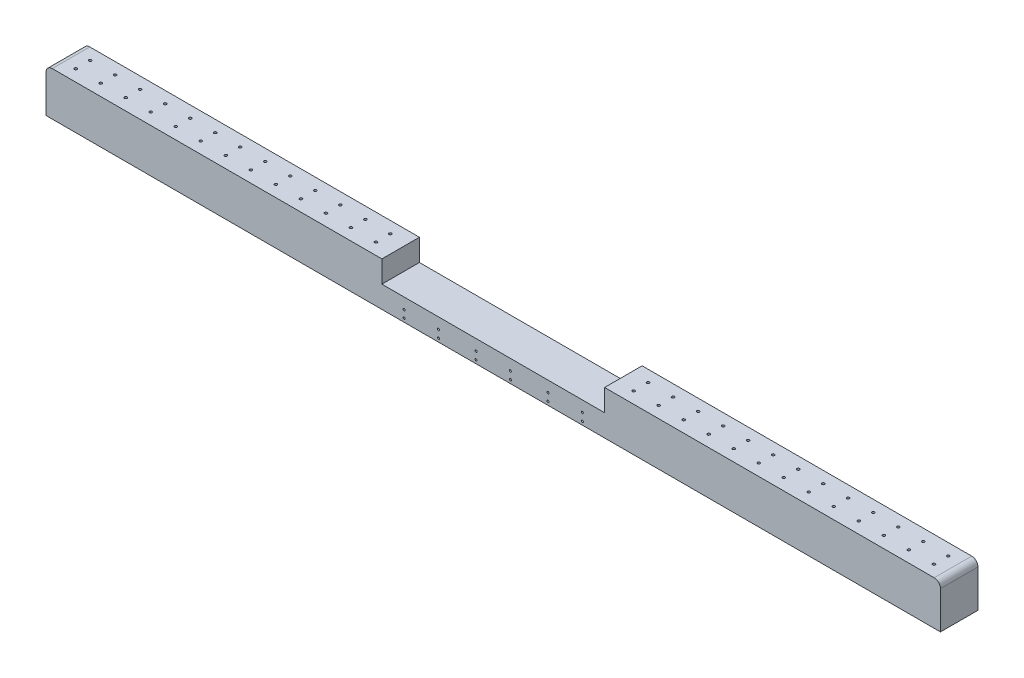
from build123d import *

# Parameters (mm, degrees)
SKETCH1_W                      = 1430
SKETCH1_H                      = 60
BOSS_EXTRUDE1_DEPTH            = 35
SKETCH2_W                      = 356
SKETCH2_H                      = 60
CUT_EXTRUDE1_DEPTH             = 35
M5X0_8_TAPPED_HOLE2_D          = 4.2
LPATTERN1_COUNT                = 13
LPATTERN1_PITCH                = 40
MIRROR1_COPY_1_D               = 4.2
MIRROR1_COPY_2_D               = 4.2
MIRROR1_COPY_3_D               = 4.2
MIRROR1_COPY_4_D               = 4.2
MIRROR1_COPY_5_D               = 4.2
MIRROR1_COPY_6_D               = 4.2
MIRROR1_COPY_7_D               = 4.2
MIRROR1_COPY_8_D               = 4.2
MIRROR1_COPY_9_D               = 4.2
MIRROR1_COPY_10_D              = 4.2
MIRROR1_COPY_11_D              = 4.2
MIRROR1_COPY_12_D              = 4.2
M4X0_7_TAPPED_HOLE1_AT_2_COUNT = 2
M4X0_7_TAPPED_HOLE1_AT_2_PITCH = 12
M4X0_7_TAPPED_HOLE1_AT_3_COUNT = 2
M4X0_7_TAPPED_HOLE1_AT_3_PITCH = 55
M4X0_7_TAPPED_HOLE1_AT_4_COUNT = 2
M4X0_7_TAPPED_HOLE1_AT_4_PITCH = 56.29387178
M4X0_7_TAPPED_HOLE1_AT_5_COUNT = 2
M4X0_7_TAPPED_HOLE1_AT_5_PITCH = 115
M4X0_7_TAPPED_HOLE1_AT_6_COUNT = 2
M4X0_7_TAPPED_HOLE1_AT_6_PITCH = 115.62439189
FILLET1_R                      = 10


with BuildPart() as part:
    # Sketch1 → Boss-Extrude1 (new body, symmetric)
    with BuildSketch(Plane(origin=(0, 0, 0), x_dir=(1, 0, 0), z_dir=(0, 1, 0))):
        Rectangle(SKETCH1_W, SKETCH1_H)
    extrude(amount=BOSS_EXTRUDE1_DEPTH, both=True)

    # Sketch2 → Cut-Extrude1 (cut)
    with BuildSketch(Plane(origin=(0, 35, 0), x_dir=(1, 0, 0), z_dir=(0, 1, 0))):
        Rectangle(SKETCH2_W, SKETCH2_H)
    extrude(amount=-CUT_EXTRUDE1_DEPTH, mode=Mode.SUBTRACT)

    # M5x0.8 Tapped Hole2 (through all)
    with Locations(Plane(origin=(0, 35, 0), x_dir=(1, 0, 0), z_dir=(0, 1, 0))):
        with Locations((205.9918251, 11.5), (205.9918251, -11.5)):
            m5x0_8_tapped_hole2 = Hole(M5X0_8_TAPPED_HOLE2_D / 2)

    # LPattern1: M5x0.8 Tapped Hole2 ×13
    with Locations(*[(i * LPATTERN1_PITCH, 0, 0) for i in range(1, LPATTERN1_COUNT)]):
        add(m5x0_8_tapped_hole2, mode=Mode.SUBTRACT)

    # Mirror1: M5x0.8 Tapped Hole2 across plane
    add(m5x0_8_tapped_hole2.mirror(Plane(origin=(0, 0, 0), x_dir=(0, 0, 1), z_dir=(1, 0, 0))), mode=Mode.SUBTRACT)

    # Mirror1 copy 1 (through all)
    with Locations(Plane(origin=(-40, 35, 0), x_dir=(-1, 0, 0), z_dir=(0, 1, 0))):
        with Locations((205.9918251, -11.5), (205.9918251, 11.5)):
            Hole(MIRROR1_COPY_1_D / 2)

    # Mirror1 copy 2 (through all)
    with Locations(Plane(origin=(-80, 35, 0), x_dir=(-1, 0, 0), z_dir=(0, 1, 0))):
        with Locations((205.9918251, -11.5), (205.9918251, 11.5)):
            Hole(MIRROR1_COPY_2_D / 2)

    # Mirror1 copy 3 (through all)
    with Locations(Plane(origin=(-120, 35, 0), x_dir=(-1, 0, 0), z_dir=(0, 1, 0))):
        with Locations((205.9918251, -11.5), (205.9918251, 11.5)):
            Hole(MIRROR1_COPY_3_D / 2)

    # Mirror1 copy 4 (through all)
    with Locations(Plane(origin=(-160, 35, 0), x_dir=(-1, 0, 0), z_dir=(0, 1, 0))):
        with Locations((205.9918251, -11.5), (205.9918251, 11.5)):
            Hole(MIRROR1_COPY_4_D / 2)

    # Mirror1 copy 5 (through all)
    with Locations(Plane(origin=(-200, 35, 0), x_dir=(-1, 0, 0), z_dir=(0, 1, 0))):
        with Locations((205.9918251, -11.5), (205.9918251, 11.5)):
            Hole(MIRROR1_COPY_5_D / 2)

    # Mirror1 copy 6 (through all)
    with Locations(Plane(origin=(-240, 35, 0), x_dir=(-1, 0, 0), z_dir=(0, 1, 0))):
        with Locations((205.9918251, -11.5), (205.9918251, 11.5)):
            Hole(MIRROR1_COPY_6_D / 2)

    # Mirror1 copy 7 (through all)
    with Locations(Plane(origin=(-280, 35, 0), x_dir=(-1, 0, 0), z_dir=(0, 1, 0))):
        with Locations((205.9918251, -11.5), (205.9918251, 11.5)):
            Hole(MIRROR1_COPY_7_D / 2)

    # Mirror1 copy 8 (through all)
    with Locations(Plane(origin=(-320, 35, 0), x_dir=(-1, 0, 0), z_dir=(0, 1, 0))):
        with Locations((205.9918251, -11.5), (205.9918251, 11.5)):
            Hole(MIRROR1_COPY_8_D / 2)

    # Mirror1 copy 9 (through all)
    with Locations(Plane(origin=(-360, 35, 0), x_dir=(-1, 0, 0), z_dir=(0, 1, 0))):
        with Locations((205.9918251, -11.5), (205.9918251, 11.5)):
            Hole(MIRROR1_COPY_9_D / 2)

    # Mirror1 copy 10 (through all)
    with Locations(Plane(origin=(-400, 35, 0), x_dir=(-1, 0, 0), z_dir=(0, 1, 0))):
        with Locations((205.9918251, -11.5), (205.9918251, 11.5)):
            Hole(MIRROR1_COPY_10_D / 2)

    # Mirror1 copy 11 (through all)
    with Locations(Plane(origin=(-440, 35, 0), x_dir=(-1, 0, 0), z_dir=(0, 1, 0))):
        with Locations((205.9918251, -11.5), (205.9918251, 11.5)):
            Hole(MIRROR1_COPY_11_D / 2)

    # Mirror1 copy 12 (through all)
    with Locations(Plane(origin=(-480, 35, 0), x_dir=(-1, 0, 0), z_dir=(0, 1, 0))):
        with Locations((205.9918251, -11.5), (205.9918251, 11.5)):
            Hole(MIRROR1_COPY_12_D / 2)

    # Sketch10 → M4x0.7 Tapped Hole1 (revolve, cut)
    with BuildSketch(Plane(origin=(142.5, -17.5, 30), x_dir=(0, -1, 0), z_dir=(1, 0, 0))):
        Polygon((0, 0), (0, 15.991420021), (1.65, 15), (1.65, 0), align=None)
    m4x0_7_tapped_hole1 = revolve(axis=Axis((142.5, -17.5, 36.35), (0, 0, -1)), mode=Mode.SUBTRACT)

    # M4x0.7 Tapped Hole1 at 2: M4x0.7 Tapped Hole1 ×2
    with Locations(*[(0, -i * M4X0_7_TAPPED_HOLE1_AT_2_PITCH, 0) for i in range(1, M4X0_7_TAPPED_HOLE1_AT_2_COUNT)]):
        add(m4x0_7_tapped_hole1, mode=Mode.SUBTRACT)

    # M4x0.7 Tapped Hole1 at 3: M4x0.7 Tapped Hole1 ×2
    with Locations(*[(-i * M4X0_7_TAPPED_HOLE1_AT_3_PITCH, 0, 0) for i in range(1, M4X0_7_TAPPED_HOLE1_AT_3_COUNT)]):
        add(m4x0_7_tapped_hole1, mode=Mode.SUBTRACT)

    # M4x0.7 Tapped Hole1 at 4: M4x0.7 Tapped Hole1 ×2
    with Locations(*[Vector(-0.977015761, -0.213167075, 0) * (i * M4X0_7_TAPPED_HOLE1_AT_4_PITCH) for i in range(1, M4X0_7_TAPPED_HOLE1_AT_4_COUNT)]):
        add(m4x0_7_tapped_hole1, mode=Mode.SUBTRACT)

    # M4x0.7 Tapped Hole1 at 5: M4x0.7 Tapped Hole1 ×2
    with Locations(*[(-i * M4X0_7_TAPPED_HOLE1_AT_5_PITCH, 0, 0) for i in range(1, M4X0_7_TAPPED_HOLE1_AT_5_COUNT)]):
        add(m4x0_7_tapped_hole1, mode=Mode.SUBTRACT)

    # M4x0.7 Tapped Hole1 at 6: M4x0.7 Tapped Hole1 ×2
    with Locations(*[Vector(-0.994599826, -0.10378433, 0) * (i * M4X0_7_TAPPED_HOLE1_AT_6_PITCH) for i in range(1, M4X0_7_TAPPED_HOLE1_AT_6_COUNT)]):
        add(m4x0_7_tapped_hole1, mode=Mode.SUBTRACT)

    # Mirror2: M4x0.7 Tapped Hole1 across plane
    add(m4x0_7_tapped_hole1.mirror(Plane(origin=(0, 0, 0), x_dir=(0, 0, 1), z_dir=(1, 0, 0))), mode=Mode.SUBTRACT)

    # Mirror2 copy 1 sketch → Mirror2 copy 1 (revolve, cut)
    with BuildSketch(Plane(origin=(-142.5, -29.5, 30), x_dir=(0, -1, 0), z_dir=(-1, 0, 0))):
        Polygon((0, 0), (0, -15.991420021), (1.65, -15), (1.65, 0), align=None)
    revolve(axis=Axis((-142.5, -29.5, 36.35), (0, 0, 1)), mode=Mode.SUBTRACT)

    # Mirror2 copy 2 sketch → Mirror2 copy 2 (revolve, cut)
    with BuildSketch(Plane(origin=(-87.5, -17.5, 30), x_dir=(0, -1, 0), z_dir=(-1, 0, 0))):
        Polygon((0, 0), (0, -15.991420021), (1.65, -15), (1.65, 0), align=None)
    revolve(axis=Axis((-87.5, -17.5, 36.35), (0, 0, 1)), mode=Mode.SUBTRACT)

    # Mirror2 copy 3 sketch → Mirror2 copy 3 (revolve, cut)
    with BuildSketch(Plane(origin=(-87.5, -29.5, 30), x_dir=(0, -1, 0), z_dir=(-1, 0, 0))):
        Polygon((0, 0), (0, -15.991420021), (1.65, -15), (1.65, 0), align=None)
    revolve(axis=Axis((-87.5, -29.5, 36.35), (0, 0, 1)), mode=Mode.SUBTRACT)

    # Mirror2 copy 4 sketch → Mirror2 copy 4 (revolve, cut)
    with BuildSketch(Plane(origin=(-27.5, -17.5, 30), x_dir=(0, -1, 0), z_dir=(-1, 0, 0))):
        Polygon((0, 0), (0, -15.991420021), (1.65, -15), (1.65, 0), align=None)
    revolve(axis=Axis((-27.5, -17.5, 36.35), (0, 0, 1)), mode=Mode.SUBTRACT)

    # Mirror2 copy 5 sketch → Mirror2 copy 5 (revolve, cut)
    with BuildSketch(Plane(origin=(-27.5, -29.5, 30), x_dir=(0, -1, 0), z_dir=(-1, 0, 0))):
        Polygon((0, 0), (0, -15.991420021), (1.65, -15), (1.65, 0), align=None)
    revolve(axis=Axis((-27.5, -29.5, 36.35), (0, 0, 1)), mode=Mode.SUBTRACT)

    # Mirror3: M4x0.7 Tapped Hole1 across plane
    add(m4x0_7_tapped_hole1.mirror(Plane.XY), mode=Mode.SUBTRACT)

    # Mirror3 copy 1 sketch → Mirror3 copy 1 (revolve, cut)
    with BuildSketch(Plane(origin=(-142.5, -17.5, -30), x_dir=(0, -1, 0), z_dir=(-1, 0, 0))):
        Polygon((0, 0), (0, 15.991420021), (1.65, 15), (1.65, 0), align=None)
    revolve(axis=Axis((-142.5, -17.5, -36.35), (0, 0, 1)), mode=Mode.SUBTRACT)

    # Mirror3 copy 2 sketch → Mirror3 copy 2 (revolve, cut)
    with BuildSketch(Plane(origin=(-142.5, -29.5, -30), x_dir=(0, -1, 0), z_dir=(-1, 0, 0))):
        Polygon((0, 0), (0, 15.991420021), (1.65, 15), (1.65, 0), align=None)
    revolve(axis=Axis((-142.5, -29.5, -36.35), (0, 0, 1)), mode=Mode.SUBTRACT)

    # Mirror3 copy 3 sketch → Mirror3 copy 3 (revolve, cut)
    with BuildSketch(Plane(origin=(-87.5, -17.5, -30), x_dir=(0, -1, 0), z_dir=(-1, 0, 0))):
        Polygon((0, 0), (0, 15.991420021), (1.65, 15), (1.65, 0), align=None)
    revolve(axis=Axis((-87.5, -17.5, -36.35), (0, 0, 1)), mode=Mode.SUBTRACT)

    # Mirror3 copy 4 sketch → Mirror3 copy 4 (revolve, cut)
    with BuildSketch(Plane(origin=(-87.5, -29.5, -30), x_dir=(0, -1, 0), z_dir=(-1, 0, 0))):
        Polygon((0, 0), (0, 15.991420021), (1.65, 15), (1.65, 0), align=None)
    revolve(axis=Axis((-87.5, -29.5, -36.35), (0, 0, 1)), mode=Mode.SUBTRACT)

    # Mirror3 copy 5 sketch → Mirror3 copy 5 (revolve, cut)
    with BuildSketch(Plane(origin=(-27.5, -17.5, -30), x_dir=(0, -1, 0), z_dir=(-1, 0, 0))):
        Polygon((0, 0), (0, 15.991420021), (1.65, 15), (1.65, 0), align=None)
    revolve(axis=Axis((-27.5, -17.5, -36.35), (0, 0, 1)), mode=Mode.SUBTRACT)

    # Mirror3 copy 6 sketch → Mirror3 copy 6 (revolve, cut)
    with BuildSketch(Plane(origin=(-27.5, -29.5, -30), x_dir=(0, -1, 0), z_dir=(-1, 0, 0))):
        Polygon((0, 0), (0, 15.991420021), (1.65, 15), (1.65, 0), align=None)
    revolve(axis=Axis((-27.5, -29.5, -36.35), (0, 0, 1)), mode=Mode.SUBTRACT)

    # Mirror3 copy 7 sketch → Mirror3 copy 7 (revolve, cut)
    with BuildSketch(Plane(origin=(142.5, -29.5, -30), x_dir=(0, -1, 0), z_dir=(1, 0, 0))):
        Polygon((0, 0), (0, -15.991420021), (1.65, -15), (1.65, 0), align=None)
    revolve(axis=Axis((142.5, -29.5, -36.35), (0, 0, -1)), mode=Mode.SUBTRACT)

    # Mirror3 copy 8 sketch → Mirror3 copy 8 (revolve, cut)
    with BuildSketch(Plane(origin=(87.5, -17.5, -30), x_dir=(0, -1, 0), z_dir=(1, 0, 0))):
        Polygon((0, 0), (0, -15.991420021), (1.65, -15), (1.65, 0), align=None)
    revolve(axis=Axis((87.5, -17.5, -36.35), (0, 0, -1)), mode=Mode.SUBTRACT)

    # Mirror3 copy 9 sketch → Mirror3 copy 9 (revolve, cut)
    with BuildSketch(Plane(origin=(87.5, -29.5, -30), x_dir=(0, -1, 0), z_dir=(1, 0, 0))):
        Polygon((0, 0), (0, -15.991420021), (1.65, -15), (1.65, 0), align=None)
    revolve(axis=Axis((87.5, -29.5, -36.35), (0, 0, -1)), mode=Mode.SUBTRACT)

    # Mirror3 copy 10 sketch → Mirror3 copy 10 (revolve, cut)
    with BuildSketch(Plane(origin=(27.5, -17.5, -30), x_dir=(0, -1, 0), z_dir=(1, 0, 0))):
        Polygon((0, 0), (0, -15.991420021), (1.65, -15), (1.65, 0), align=None)
    revolve(axis=Axis((27.5, -17.5, -36.35), (0, 0, -1)), mode=Mode.SUBTRACT)

    # Mirror3 copy 11 sketch → Mirror3 copy 11 (revolve, cut)
    with BuildSketch(Plane(origin=(27.5, -29.5, -30), x_dir=(0, -1, 0), z_dir=(1, 0, 0))):
        Polygon((0, 0), (0, -15.991420021), (1.65, -15), (1.65, 0), align=None)
    revolve(axis=Axis((27.5, -29.5, -36.35), (0, 0, -1)), mode=Mode.SUBTRACT)

    # Fillet1
    fillet1_edges = [part.edges().sort_by_distance(p)[0] for p in [
        (715, 35, 0),
        (-715, 35, 0),
    ]]
    fillet(fillet1_edges, radius=FILLET1_R)


solid = part.part
